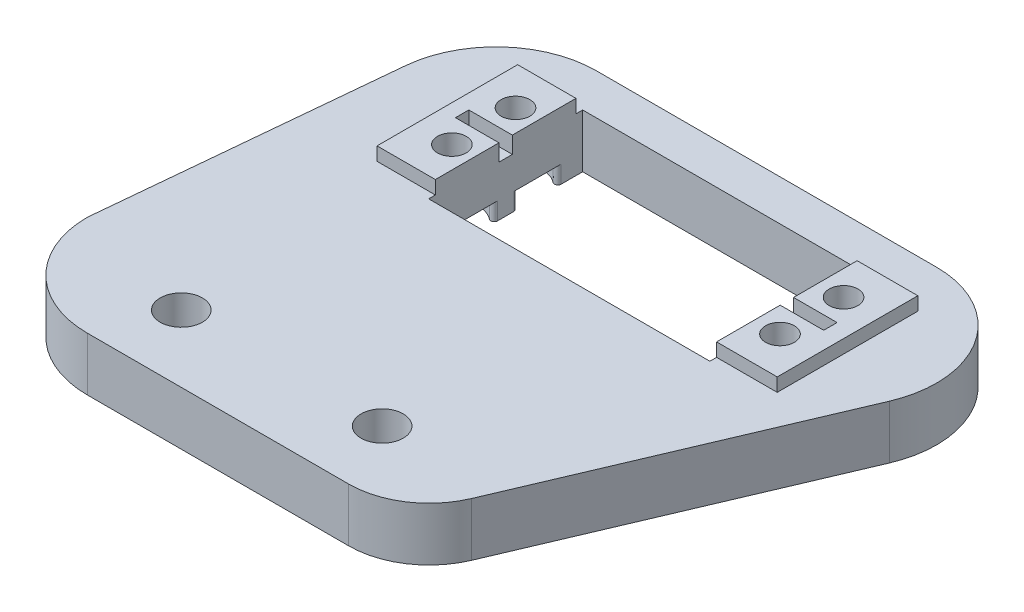
from build123d import *

# Parameters (mm, degrees)
BOSS_EXTRUDE1_DEPTH     = 8
SKETCH2_R               = 3.15
CUT_EXTRUDE1_DEPTH      = 8
SKETCH3_W               = 9.706264803
SKETCH3_H               = 21
SKETCH3_R               = 2.15
BOSS_EXTRUDE3_DEPTH     = 2
SKETCH4_W               = 42
SKETCH4_H               = 23
CUT_EXTRUDE4_DEPTH      = 16
CUT_EXTRUDE4_DEPTH_BACK = 16
CUT_EXTRUDE5_DEPTH      = 2.5
SKETCH8_R               = 2.15
CUT_EXTRUDE8_DEPTH      = 21.6
SKETCH9_R               = 4
CUT_EXTRUDE9_DEPTH      = 2.6
FILLET2_R               = 0.5


with BuildPart() as part:
    # Sketch1 → Boss-Extrude1 (new body)
    with BuildSketch(Plane(origin=(0, 0, 0), x_dir=(1, 0, 0), z_dir=(0, 1, 0))):
        with BuildLine():
            ThreePointArc((10.980762114, 15), (15.374160396, 4.393398282), (25.980762114, 0))
            Line((25.980762114, 0), (65.009618943, 0))
            ThreePointArc((65.009618943, 0), (71.630509288, 1.991812799), (76.05347061, 7.306031492))
            Line((76.05347061, 7.306031492), (90.667824887, 41.690318597))
            Line((90.667824887, 41.690318597), (92.106342015, 45.074825706))
            Line((92.106342015, 45.074825706), (94.659597169, 51.082060554))
            ThreePointArc((94.659597169, 51.082060554), (93.365016587, 65.225634119), (80.854782585, 71.949521188))
            Line((80.854782585, 71.949521188), (30.067550518, 71.949521188))
            ThreePointArc((30.067550518, 71.949521188), (19.979275987, 68.05027418), (15.13589136, 58.37975012))
            Line((15.13589136, 58.37975012), (14.014444666, 46.671792448))
            Line((14.014444666, 46.671792448), (10.980762114, 15))
        make_face()
    extrude(amount=BOSS_EXTRUDE1_DEPTH)

    # Sketch2 → Cut-Extrude1 (cut)
    with BuildSketch(Plane(origin=(0, 8, 0), x_dir=(1, 0, 0), z_dir=(0, 1, 0))):
        with Locations((30, 10)):
            Circle(SKETCH2_R)
        with Locations((60, 10)):
            Circle(SKETCH2_R)
    extrude(amount=-CUT_EXTRUDE1_DEPTH, mode=Mode.SUBTRACT)

    # Sketch3 → Boss-Extrude3 (add)
    with BuildSketch(Plane(origin=(0, 8, 0), x_dir=(1, 0, 0), z_dir=(0, 1, 0))):
        with Locations((30.236867599, 54.358166274)):
            Rectangle(SKETCH3_W, SKETCH3_H)
        with Locations((30.81, 49.608166274)):
            Circle(SKETCH3_R, mode=Mode.SUBTRACT)
        with Locations((30.81, 59.108166274)):
            Circle(SKETCH3_R, mode=Mode.SUBTRACT)
        Polygon((75.15, 43.858166274), (85.15, 43.858166274), (85.15, 62.709957967), (85.15, 64.858166274), (75.15, 64.858166274), (75.11, 54.358166274), align=None)
        with Locations((79.81, 49.608166274)):
            Circle(SKETCH3_R, mode=Mode.SUBTRACT)
        with Locations((79.81, 59.108166274)):
            Circle(SKETCH3_R, mode=Mode.SUBTRACT)
    extrude(amount=BOSS_EXTRUDE3_DEPTH)

    # Sketch4 → Cut-Extrude4 (cut, two sides)
    with BuildSketch(Plane(origin=(0, 8, 0), x_dir=(1, 0, 0), z_dir=(0, 1, 0))) as cut_extrude4_sk:
        with Locations((55.09, 54.358166274)):
            Rectangle(SKETCH4_W, SKETCH4_H)
    extrude(amount=CUT_EXTRUDE4_DEPTH, mode=Mode.SUBTRACT)
    extrude(cut_extrude4_sk.sketch, amount=-CUT_EXTRUDE4_DEPTH_BACK, mode=Mode.SUBTRACT)

    # Sketch5 → Cut-Extrude5 (cut)
    with BuildSketch(Plane(origin=(0, 10, 0), x_dir=(1, 0, 0), z_dir=(0, 1, 0))):
        Polygon((76.09, 54.358166274), (76.09, 55.358166274), (82.59, 55.358166274), (82.59, 53.358166274), (76.09, 53.358166274), align=None)
        Polygon((27.59, 54.358166274), (27.59, 55.358166274), (34.09, 55.358166274), (34.09, 53.358166274), (27.59, 53.358166274), align=None)
    extrude(amount=-CUT_EXTRUDE5_DEPTH, mode=Mode.SUBTRACT)

    # Sketch8 → Cut-Extrude8 (cut)
    with BuildSketch(Plane(origin=(0, 8, 0), x_dir=(1, 0, 0), z_dir=(0, 1, 0))):
        with Locations((30.81, 49.608166274)):
            Circle(SKETCH8_R)
        with Locations((30.81, 59.108166274)):
            Circle(SKETCH8_R)
        with Locations((79.81, 59.108166274)):
            Circle(SKETCH8_R)
        with Locations((79.81, 49.608166274)):
            Circle(SKETCH8_R)
    extrude(amount=-CUT_EXTRUDE8_DEPTH, mode=Mode.SUBTRACT)

    # Sketch9 → Cut-Extrude9 (cut)
    with BuildSketch(Plane.XZ):
        with Locations((30.81, -59.108166274)):
            Circle(SKETCH9_R)
        with Locations((30.81, -49.608166274)):
            Circle(SKETCH9_R)
        with Locations((79.81, -59.108166274)):
            Circle(SKETCH9_R)
        with Locations((79.81, -49.608166274)):
            Circle(SKETCH9_R)
    extrude(amount=-CUT_EXTRUDE9_DEPTH, mode=Mode.SUBTRACT)

    # Fillet2
    fillet2_edges = [part.edges().sort_by_distance(p)[0] for p in [
        (76.09, 1.3, -51.07840435),
        (76.09, 1.3, -48.137928198),
        (76.09, 1.3, -60.57840435),
        (76.09, 1.3, -57.637928198),
        (34.09, 1.3, -56.818712191),
        (34.09, 1.3, -61.397620358),
        (34.09, 1.3, -47.318712191),
        (34.09, 1.3, -51.897620358),
    ]]
    fillet(fillet2_edges, radius=FILLET2_R)


solid = part.part
